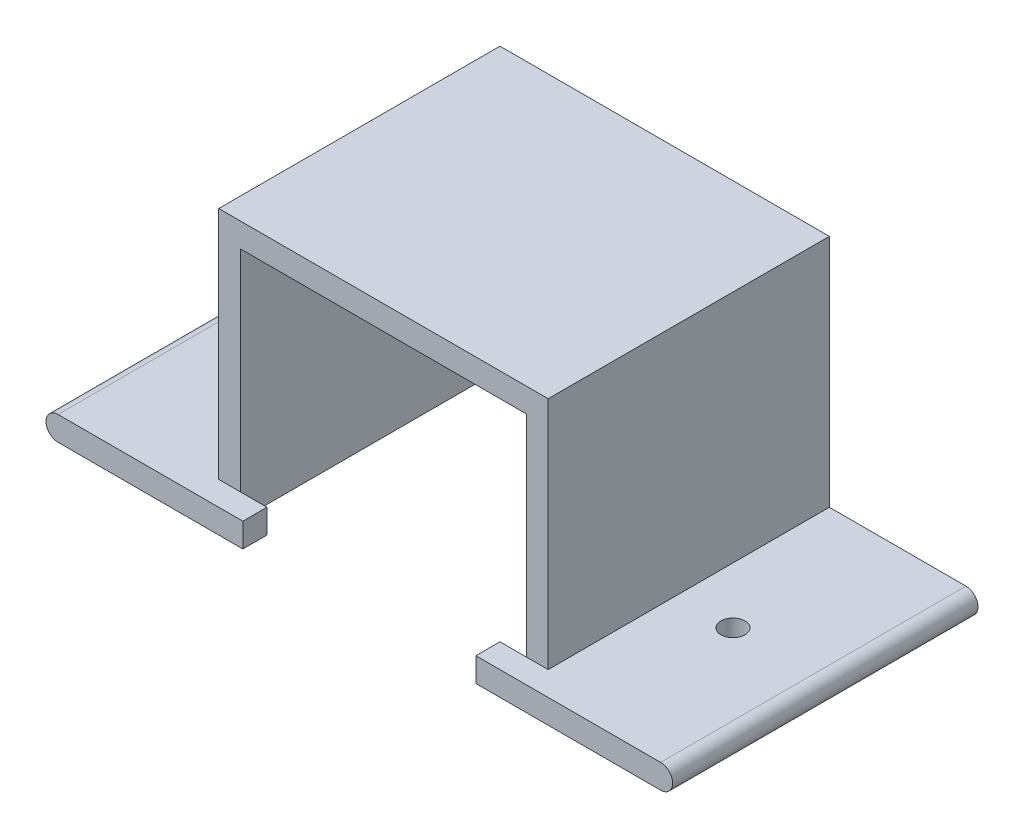
from build123d import *

# Parameters (mm, degrees)
BOSS_EXTRUDE1_DEPTH = 32
SKETCH2_W           = 35.6
SKETCH2_H           = 29.2
BOSS_EXTRUDE2_DEPTH = 3
BOSS_EXTRUDE3_DEPTH = 3
SKETCH4_R           = 1.5
CUT_EXTRUDE1_DEPTH  = 4


with BuildPart() as part:
    # Sketch1 → Boss-Extrude1 (new body)
    with BuildSketch(Plane.XY):
        with BuildLine():
            Line((0, 0), (-19.7, 0))
            Line((-19.7, 0), (-19.7, 29.2))
            Line((-19.7, 29.2), (-20, 29.2))
            Line((-20, 29.2), (-55, 29.2))
            Line((-55, 29.2), (-55.3, 29.2))
            Line((-55.3, 29.2), (-55.3, 0))
            Line((-55.3, 0), (-75, 0))
            ThreePointArc((-75, 0), (-76.5, 1.5), (-75, 3))
            Line((-75, 3), (-58, 3))
            Line((-58, 3), (-58, 30.2))
            Line((-58, 30.2), (-58, 32.2))
            Line((-58, 32.2), (-17, 32.2))
            Line((-17, 32.2), (-17, 30.2))
            Line((-17, 30.2), (-17, 3))
            Line((-17, 3), (0, 3))
            ThreePointArc((0, 3), (1.5, 1.5), (0, 0))
        make_face()
    extrude(amount=BOSS_EXTRUDE1_DEPTH)

    # Sketch2 → Boss-Extrude2 (add)
    with BuildSketch(Plane(origin=(0, 0, 0), x_dir=(-1, 0, 0), z_dir=(0, 0, -1))):
        with Locations((37.5, 14.6)):
            Rectangle(SKETCH2_W, SKETCH2_H)
        with BuildLine():
            Line((17, 3), (0, 3))
            ThreePointArc((0, 3), (-1.5, 1.5), (0, 0))
            Line((0, 0), (19.7, 0))
            Line((19.7, 0), (19.7, 29.2))
            Line((19.7, 29.2), (55.3, 29.2))
            Line((55.3, 29.2), (55.3, 0))
            Line((55.3, 0), (75, 0))
            ThreePointArc((75, 0), (76.5, 1.5), (75, 3))
            Line((75, 3), (58, 3))
            Line((58, 3), (58, 32.2))
            Line((58, 32.2), (17, 32.2))
            Line((17, 32.2), (17, 3))
        make_face()
    extrude(amount=BOSS_EXTRUDE2_DEPTH)

    # Sketch3 → Boss-Extrude3 (add)
    with BuildSketch(Plane.XY.offset(32)):
        with BuildLine():
            Line((-20, 0), (-23, 0))
            Line((-23, 0), (-23, 3))
            Line((-23, 3), (-20, 3))
            Line((-20, 3), (0, 3))
            ThreePointArc((0, 3), (1.5, 1.5), (0, 0))
            Line((0, 0), (-20, 0))
        make_face()
        with BuildLine():
            Line((-55, 0), (-75, 0))
            ThreePointArc((-75, 0), (-76.5, 1.5), (-75, 3))
            Line((-75, 3), (-55, 3))
            Line((-55, 3), (-52, 3))
            Line((-52, 3), (-52, 0))
            Line((-52, 0), (-55, 0))
        make_face()
    extrude(amount=BOSS_EXTRUDE3_DEPTH)

    # Sketch4 → Cut-Extrude1 (cut)
    with BuildSketch(Plane.XZ):
        with Locations((-65, 16)):
            Circle(SKETCH4_R)
        with Locations((-10, 16)):
            Circle(SKETCH4_R)
    extrude(amount=-CUT_EXTRUDE1_DEPTH, mode=Mode.SUBTRACT)


solid = part.part
